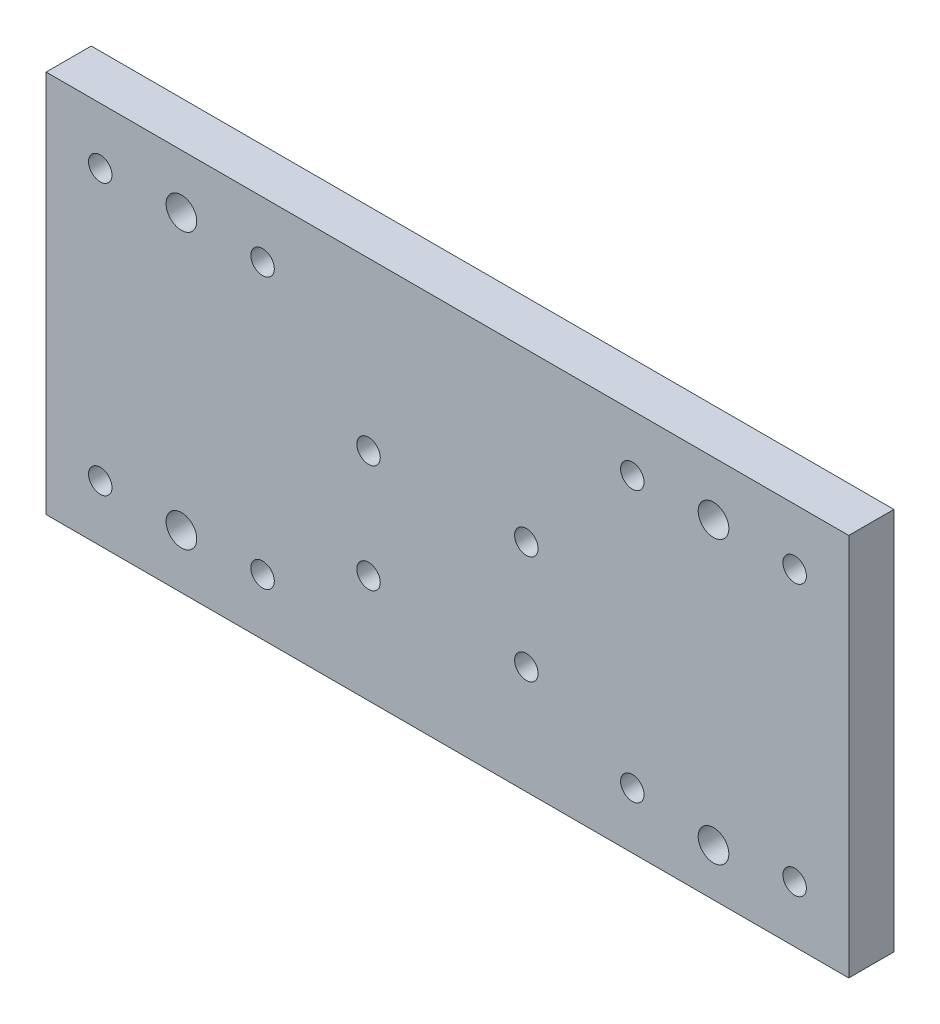
from build123d import *

# Parameters (mm, degrees)
SKETCH1_W           = 178
SKETCH1_H           = 85
SKETCH1_R           = 2.6
BOSS_EXTRUDE1_DEPTH = 10
M8_TAPPED_HOLE1_D   = 6.8


with BuildPart() as part:
    # Sketch1 → Boss-Extrude1 (new body)
    with BuildSketch(Plane.XY):
        Rectangle(SKETCH1_W, SKETCH1_H)
        with Locations((-77, -30)):
            Circle(SKETCH1_R, mode=Mode.SUBTRACT)
        with Locations((-41, -30)):
            Circle(SKETCH1_R, mode=Mode.SUBTRACT)
        with Locations((-41, 30)):
            Circle(SKETCH1_R, mode=Mode.SUBTRACT)
        with Locations((-77, 30)):
            Circle(SKETCH1_R, mode=Mode.SUBTRACT)
        with Locations((-17.5, -18.5)):
            Circle(SKETCH1_R, mode=Mode.SUBTRACT)
        with Locations((17.5, -18.5)):
            Circle(SKETCH1_R, mode=Mode.SUBTRACT)
        with Locations((17.5, 5.5)):
            Circle(SKETCH1_R, mode=Mode.SUBTRACT)
        with Locations((-17.5, 5.5)):
            Circle(SKETCH1_R, mode=Mode.SUBTRACT)
        with Locations((77, -30)):
            Circle(SKETCH1_R, mode=Mode.SUBTRACT)
        with Locations((41, -30)):
            Circle(SKETCH1_R, mode=Mode.SUBTRACT)
        with Locations((41, 30)):
            Circle(SKETCH1_R, mode=Mode.SUBTRACT)
        with Locations((77, 30)):
            Circle(SKETCH1_R, mode=Mode.SUBTRACT)
    extrude(amount=BOSS_EXTRUDE1_DEPTH)

    # M8 Tapped Hole1 (through all)
    with Locations(Plane.XY.offset(10)):
        with Locations((59, 30.5), (-59, 30.5), (-59, -30.5), (59, -32)):
            Hole(M8_TAPPED_HOLE1_D / 2)


solid = part.part
